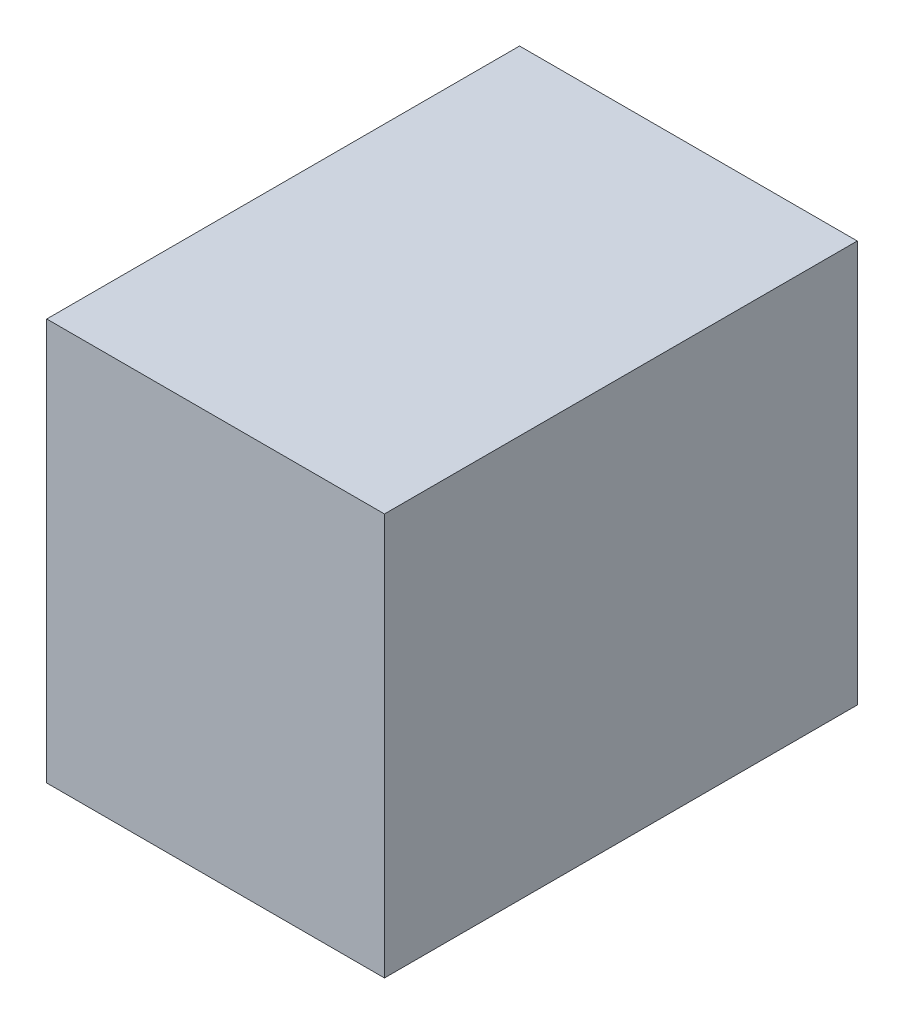
from build123d import *

# Parameters (mm, degrees)
SKETCH1_W           = 5
SKETCH1_H           = 7
BOSS_EXTRUDE1_DEPTH = 5.95


with BuildPart() as part:
    # Sketch1 → Boss-Extrude1 (new body)
    with BuildSketch(Plane(origin=(0, 0, 0), x_dir=(1, 0, 0), z_dir=(0, 1, 0))):
        with Locations((2.5, 3.5)):
            Rectangle(SKETCH1_W, SKETCH1_H)
    extrude(amount=BOSS_EXTRUDE1_DEPTH)


solid = part.part
